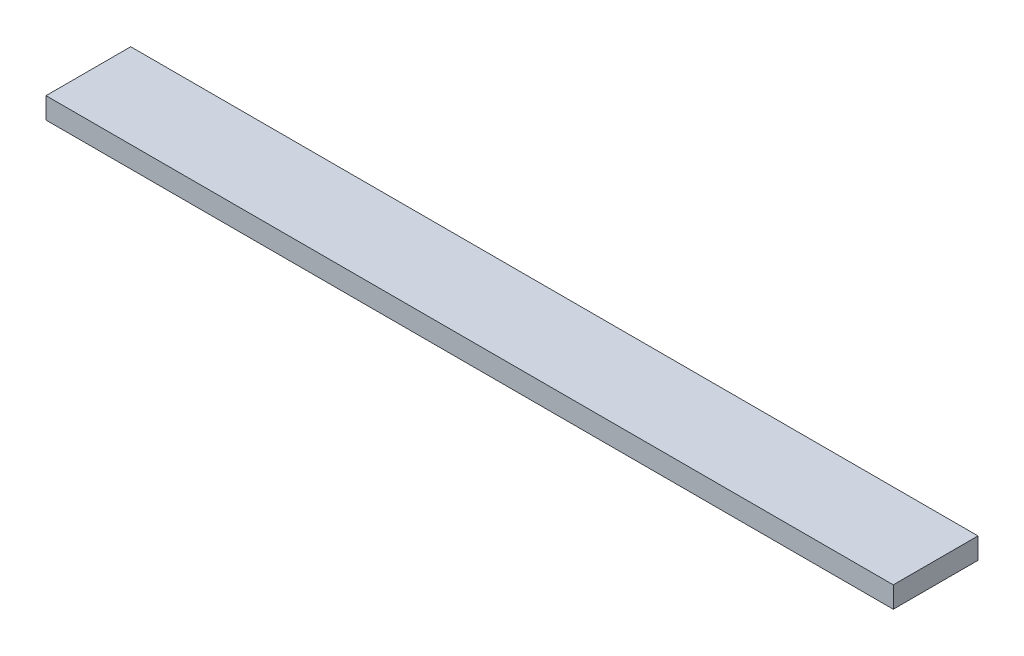
from build123d import *

# Parameters (mm, degrees)
BOSS_EXTRU_1_DEPTH      = 40
BOSS_EXTRU_1_DEPTH_BACK = 40
CHANFREIN1_SIZE         = 1.5


with BuildPart() as part:
    # Esquisse1 → Boss.-Extru.1 (new, two sides: drawn at the far end of the back side and taken through both)
    with BuildSketch(Plane(origin=(0, 0, 0), x_dir=(0, 0, -1), z_dir=(1, 0, 0)).offset(-BOSS_EXTRU_1_DEPTH_BACK)):
        Polygon((-4, 0), (4, 0), (4, -2), (2.5, -3.5), (-2.5, -3.5), (-4, -2), align=None)
    extrude(amount=BOSS_EXTRU_1_DEPTH + BOSS_EXTRU_1_DEPTH_BACK)

    # Chanfrein1
    chanfrein1_edges = [part.edges().sort_by_distance(p)[0] for p in [
        (40, -3.5, 0),
        (-40, -3.5, 0),
    ]]
    chamfer(chanfrein1_edges, length=CHANFREIN1_SIZE)


solid = part.part
